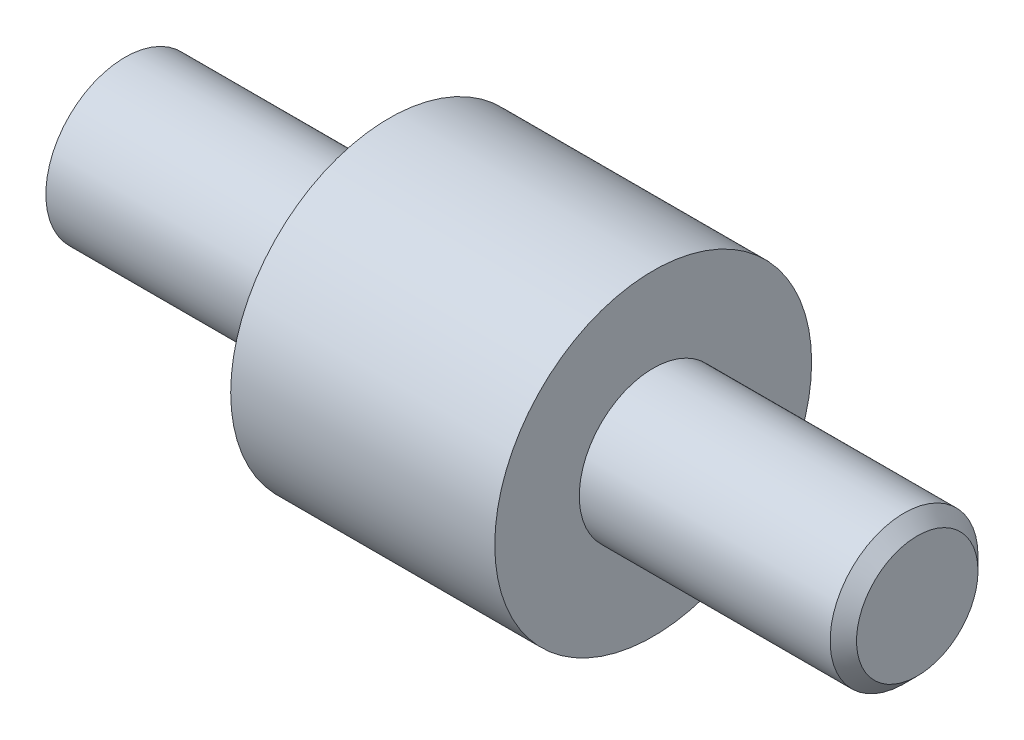
from build123d import *

# Parameters (mm, degrees)
CHANFREIN1_SIZE = 0.25


with BuildPart() as part:
    # Esquisse1 → Révolution1 (revolve)
    with BuildSketch(Plane.XY, mode=Mode.PRIVATE) as r_volution1_sk:
        Polygon((0, 0), (0, 1.5), (5, 1.5), (5, 3), (10, 3), (10, 1.4), (15, 1.4), (15, 0), align=None)
    revolve(r_volution1_sk.sketch.rotate(Axis((15, 0, 0), (-1, 0, 0)), 90), axis=Axis((15, 0, 0), (-1, 0, 0)))  # turned: the seam where the file's is

    # Chanfrein1
    chanfrein1_edges = [part.edges().sort_by_distance(p)[0] for p in [
        (15, 0, 1.4),
    ]]
    chamfer(chanfrein1_edges, length=CHANFREIN1_SIZE)


solid = part.part
